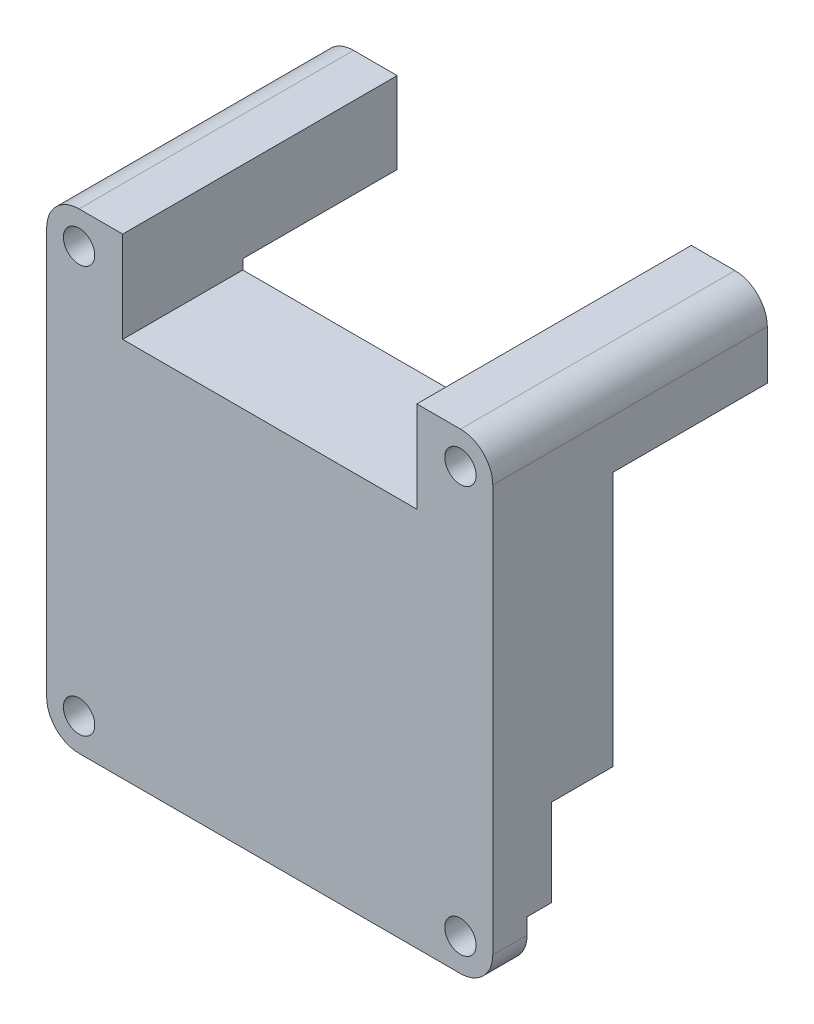
from build123d import *

# Parameters (mm, degrees)
SKICA1_R                 = 1.6
P_IDAT_VYSUNUT_M1_DEPTH  = 28
SKICA5_W                 = 33
SKICA5_H                 = 28.9
ODEBRAT_VYSUNUT_M3_DEPTH = 22
SKICA7_W                 = 30
SKICA7_H                 = 10.3
ODEBRAT_VYSUNUT_M5_DEPTH = 29
SKICA6_W                 = 47.5
SKICA6_H                 = 26
ODEBRAT_VYSUNUT_M4_DEPTH = 15.75
SKICA8_W                 = 50
SKICA8_H                 = 16
ODEBRAT_VYSUNUT_M6_DEPTH = 22
ODEBRAT_VYSUNUT_M7_DEPTH = 2.5


with BuildPart() as part:
    # Skica1 → Přidat vysunutím1 (new body)
    with BuildSketch(Plane.XY):
        with BuildLine():
            Line((19.45, -3.3), (-19.45, -3.3))
            ThreePointArc((-19.45, -3.3), (-21.783452378, -2.333452378), (-22.75, 0))
            Line((-22.75, 0), (-22.75, 41.5))
            ThreePointArc((-22.75, 41.5), (-21.783452378, 43.833452378), (-19.45, 44.8))
            Line((-19.45, 44.8), (19.45, 44.8))
            ThreePointArc((19.45, 44.8), (21.783452378, 43.833452378), (22.75, 41.5))
            Line((22.75, 41.5), (22.75, 0))
            ThreePointArc((22.75, 0), (21.783452378, -2.333452378), (19.45, -3.3))
        make_face()
        with Locations((19.45, 0)):
            Circle(SKICA1_R, mode=Mode.SUBTRACT)
        with Locations((-19.45, 0)):
            Circle(SKICA1_R, mode=Mode.SUBTRACT)
        with Locations((19.45, 41.5)):
            Circle(SKICA1_R, mode=Mode.SUBTRACT)
        with Locations((-19.45, 41.5)):
            Circle(SKICA1_R, mode=Mode.SUBTRACT)
    extrude(amount=P_IDAT_VYSUNUT_M1_DEPTH)

    # Skica5 → Odebrat vysunutím3 (cut)
    with BuildSketch(Plane.XY):
        with Locations((0, 10.15)):
            Rectangle(SKICA5_W, SKICA5_H)
    extrude(amount=ODEBRAT_VYSUNUT_M3_DEPTH, mode=Mode.SUBTRACT)

    # Skica7 → Odebrat vysunutím5 (cut, through all)
    with BuildSketch(Plane.XY):
        with Locations((0, 40.65)):
            Rectangle(SKICA7_W, SKICA7_H)
    extrude(amount=ODEBRAT_VYSUNUT_M5_DEPTH, mode=Mode.SUBTRACT)

    # Skica6 → Odebrat vysunutím4 (cut)
    with BuildSketch(Plane.XY):
        with Locations((0, 23.5)):
            Rectangle(SKICA6_W, SKICA6_H)
    extrude(amount=ODEBRAT_VYSUNUT_M4_DEPTH, mode=Mode.SUBTRACT)

    # Skica8 → Odebrat vysunutím6 (cut)
    with BuildSketch(Plane.XY):
        with Locations((0, 2.5)):
            Rectangle(SKICA8_W, SKICA8_H)
    extrude(amount=ODEBRAT_VYSUNUT_M6_DEPTH, mode=Mode.SUBTRACT)

    # Skica9 → Odebrat vysunutím7 (cut)
    with BuildSketch(Plane.XY.offset(22)):
        Polygon((-19.45, -3.233161507), (-19.45, -4.03299561), (-23.966905363, -4.03299561), (-23.966905363, 1.616580754), (-22.25, 1.616580754), (-19.45, 3.233161507), (-16.65, 1.616580754), (-16.65, -1.616580754), align=None)
    odebrat_vysunut_m7 = extrude(amount=ODEBRAT_VYSUNUT_M7_DEPTH, mode=Mode.SUBTRACT)

    # Zrcadlit1: Odebrat vysunutím7 across plane
    add(odebrat_vysunut_m7.mirror(Plane(origin=(0, 0, 0), x_dir=(0, 0, 1), z_dir=(1, 0, 0))), mode=Mode.SUBTRACT)


solid = part.part
